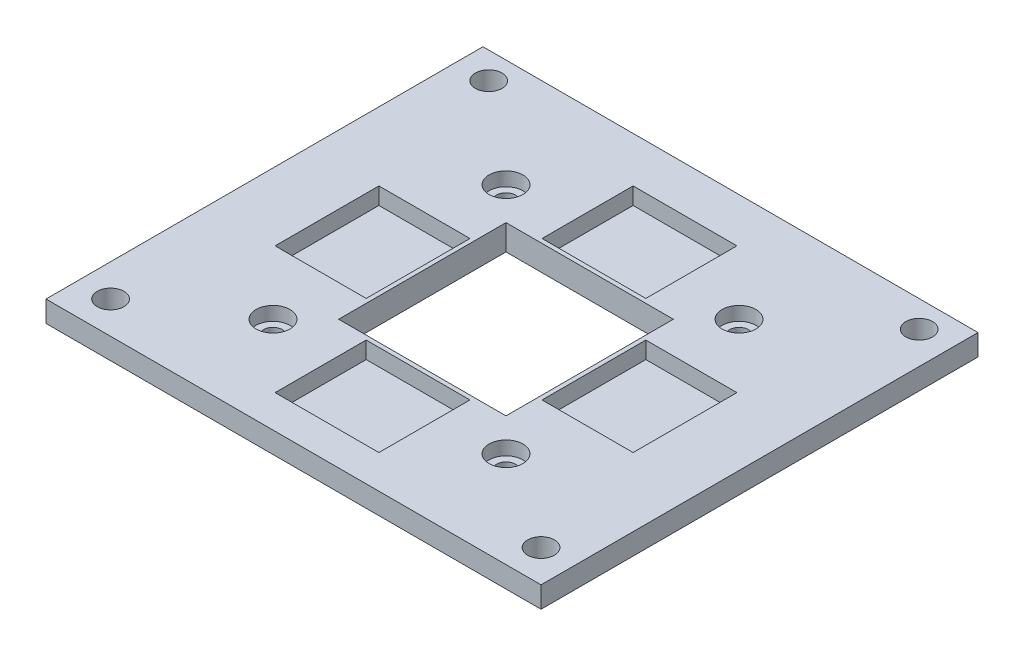
from build123d import *

# Parameters (mm, degrees)
SKETCH1_W              = 116.84
SKETCH1_H              = 103.134084814
SKETCH1_R              = 3.15
BOSS_EXTRUDE1_DEPTH    = 5
SKETCH12_W             = 85
SKETCH12_H             = 23.975046692
BOSS_EXTRUDE15_DEPTH   = 5
SKETCH17_W             = 50
SKETCH17_H             = 50
BOSS_EXTRUDE18_DEPTH   = 6
SKETCH10_W             = 39.5
SKETCH10_H             = 39.5
BOSS_EXTRUDE19_DEPTH   = 25
SKETCH19_W             = 55
SKETCH19_H             = 55
BOSS_EXTRUDE20_DEPTH   = 11
SKETCH20_R             = 2.25
BOSS_EXTRUDE22_DEPTH   = 25
BOSS_EXTRUDE22_2_DEPTH = 25
BOSS_EXTRUDE22_3_DEPTH = 25
BOSS_EXTRUDE22_4_DEPTH = 25
SKETCH21_W             = 24.5
SKETCH21_H             = 21.5
BOSS_EXTRUDE23_DEPTH   = 4
SKETCH21_W_2           = 21.5
SKETCH21_H_2           = 24.5
BOSS_EXTRUDE23_2_DEPTH = 4
BOSS_EXTRUDE23_3_DEPTH = 4
BOSS_EXTRUDE23_4_DEPTH = 4
SKETCH25_R             = 4
BOSS_EXTRUDE24_DEPTH   = 3.25
BOSS_EXTRUDE24_2_DEPTH = 3.25
BOSS_EXTRUDE24_3_DEPTH = 3.25
BOSS_EXTRUDE24_4_DEPTH = 3.25


with BuildPart() as part:
    # Sketch1 → Boss-Extrude1 (new body)
    with BuildSketch(Plane(origin=(0, 0, 0), x_dir=(1, 0, 0), z_dir=(0, 1, 0))):
        with Locations((0, 1.415042407)):
            Rectangle(SKETCH1_W, SKETCH1_H)
        with Locations((-50.8, 46.711)):
            Circle(SKETCH1_R, mode=Mode.SUBTRACT)
        with Locations((50.8, -42.532)):
            Circle(SKETCH1_R, mode=Mode.SUBTRACT)
        with Locations((-50.8, -42.532)):
            Circle(SKETCH1_R, mode=Mode.SUBTRACT)
        with Locations((50.8, 46.711)):
            Circle(SKETCH1_R, mode=Mode.SUBTRACT)
    extrude(amount=-BOSS_EXTRUDE1_DEPTH)


with BuildPart() as body_2:
    # Sketch12 → Boss-Extrude15 (new body)
    with BuildSketch(Plane(origin=(0, 0, 0), x_dir=(1, 0, 0), z_dir=(0, 1, 0))):
        with Locations((0, 58)):
            Rectangle(SKETCH12_W, SKETCH12_H)
    extrude(amount=BOSS_EXTRUDE15_DEPTH)


with BuildPart() as body_3:
    # Sketch17 → Boss-Extrude18 (new body)
    with BuildSketch(Plane(origin=(0, 0, 0), x_dir=(1, 0, 0), z_dir=(0, 1, 0))):
        Rectangle(SKETCH17_W, SKETCH17_H)
    extrude(amount=-BOSS_EXTRUDE18_DEPTH)


with BuildPart() as body_4:
    # Sketch10 → Boss-Extrude19 (new body, symmetric)
    with BuildSketch(Plane(origin=(0, 0, 0), x_dir=(1, 0, 0), z_dir=(0, 1, 0))):
        Rectangle(SKETCH10_W, SKETCH10_H)
    extrude(amount=BOSS_EXTRUDE19_DEPTH, both=True)


with BuildPart() as body_5:
    # Sketch19 → Boss-Extrude20 (new body)
    with BuildSketch(Plane(origin=(0, 0, 0), x_dir=(1, 0, 0), z_dir=(0, 1, 0))):
        Rectangle(SKETCH19_W, SKETCH19_H)
    extrude(amount=-BOSS_EXTRUDE20_DEPTH)


with BuildPart() as part_1:
    add(part.part)

    # Combine1: cut body 2
    add(body_2.part, mode=Mode.SUBTRACT)


with BuildPart() as body_3_1:
    # Body-Move/Copy4: moved
    add(body_3.part.moved(Location((0, -6, 0))))


with BuildPart() as body_5_1:
    add(body_5.part)

    # Combine4: cut body 3
    add(body_3_1.part, mode=Mode.SUBTRACT)

    # Combine7: union part
    add(part_1.part)

    # Combine8: cut body 4
    add(body_4.part, mode=Mode.SUBTRACT)


with BuildPart() as body_2_2:
    # Sketch20 → Boss-Extrude22 (new body, symmetric)
    with BuildSketch(Plane(origin=(0, 0, 0), x_dir=(1, 0, 0), z_dir=(0, 1, 0))):
        with Locations((27.5, 27.5)):
            Circle(SKETCH20_R)
    extrude(amount=BOSS_EXTRUDE22_DEPTH, both=True)


with BuildPart() as body_3_2:
    # Sketch20 → Boss-Extrude22 2 (new body, symmetric)
    with BuildSketch(Plane(origin=(0, 0, 0), x_dir=(1, 0, 0), z_dir=(0, 1, 0))):
        with Locations((27.5, -27.5)):
            Circle(SKETCH20_R)
    extrude(amount=BOSS_EXTRUDE22_2_DEPTH, both=True)


with BuildPart() as body_4_2:
    # Sketch20 → Boss-Extrude22 3 (new body, symmetric)
    with BuildSketch(Plane(origin=(0, 0, 0), x_dir=(1, 0, 0), z_dir=(0, 1, 0))):
        with Locations((-27.5, -27.5)):
            Circle(SKETCH20_R)
    extrude(amount=BOSS_EXTRUDE22_3_DEPTH, both=True)


with BuildPart() as body_5_2:
    # Sketch20 → Boss-Extrude22 4 (new body, symmetric)
    with BuildSketch(Plane(origin=(0, 0, 0), x_dir=(1, 0, 0), z_dir=(0, 1, 0))):
        with Locations((-27.5, 27.5)):
            Circle(SKETCH20_R)
    extrude(amount=BOSS_EXTRUDE22_4_DEPTH, both=True)


with BuildPart() as body_5_3:
    add(body_5_1.part)

    # Combine9: cut body 4 2, body 3 2, body 2 2, body 5 2
    add(body_4_2.part, mode=Mode.SUBTRACT)
    add(body_3_2.part, mode=Mode.SUBTRACT)
    add(body_2_2.part, mode=Mode.SUBTRACT)
    add(body_5_2.part, mode=Mode.SUBTRACT)


with BuildPart() as body_2_3:
    # Sketch21 → Boss-Extrude23 (new body)
    with BuildSketch(Plane(origin=(0, 0, 0), x_dir=(1, 0, 0), z_dir=(0, 1, 0))):
        with Locations((0, 31.5)):
            Rectangle(SKETCH21_W, SKETCH21_H)
    extrude(amount=-BOSS_EXTRUDE23_DEPTH)


with BuildPart() as body_3_3:
    # Sketch21 → Boss-Extrude23 2 (new body)
    with BuildSketch(Plane(origin=(0, 0, 0), x_dir=(1, 0, 0), z_dir=(0, 1, 0))):
        with Locations((31.5, 0)):
            Rectangle(SKETCH21_W_2, SKETCH21_H_2)
    extrude(amount=-BOSS_EXTRUDE23_2_DEPTH)


with BuildPart() as body_4_3:
    # Sketch21 → Boss-Extrude23 3 (new body)
    with BuildSketch(Plane(origin=(0, 0, 0), x_dir=(1, 0, 0), z_dir=(0, 1, 0))):
        with Locations((-31.5, 0)):
            Rectangle(SKETCH21_W_2, SKETCH21_H_2)
    extrude(amount=-BOSS_EXTRUDE23_3_DEPTH)


with BuildPart() as body_5_3_1:
    # Sketch21 → Boss-Extrude23 4 (new body)
    with BuildSketch(Plane(origin=(0, 0, 0), x_dir=(1, 0, 0), z_dir=(0, 1, 0))):
        with Locations((0, -31.5)):
            Rectangle(SKETCH21_W, SKETCH21_H)
    extrude(amount=-BOSS_EXTRUDE23_4_DEPTH)


with BuildPart() as body_5_4:
    add(body_5_3.part)

    # Combine10: cut body 3 3, body 2 3, body 5 3, body 4 3
    add(body_3_3.part, mode=Mode.SUBTRACT)
    add(body_2_3.part, mode=Mode.SUBTRACT)
    add(body_5_3_1.part, mode=Mode.SUBTRACT)
    add(body_4_3.part, mode=Mode.SUBTRACT)


with BuildPart() as body_2_4:
    # Sketch25 → Boss-Extrude24 (new body)
    with BuildSketch(Plane(origin=(0, 0, 0), x_dir=(1, 0, 0), z_dir=(0, 1, 0))):
        with Locations((27.5, 27.5)):
            Circle(SKETCH25_R)
    extrude(amount=-BOSS_EXTRUDE24_DEPTH)


with BuildPart() as body_3_4:
    # Sketch25 → Boss-Extrude24 2 (new body)
    with BuildSketch(Plane(origin=(0, 0, 0), x_dir=(1, 0, 0), z_dir=(0, 1, 0))):
        with Locations((-27.5, 27.5)):
            Circle(SKETCH25_R)
    extrude(amount=-BOSS_EXTRUDE24_2_DEPTH)


with BuildPart() as body_4_4:
    # Sketch25 → Boss-Extrude24 3 (new body)
    with BuildSketch(Plane(origin=(0, 0, 0), x_dir=(1, 0, 0), z_dir=(0, 1, 0))):
        with Locations((-27.5, -27.5)):
            Circle(SKETCH25_R)
    extrude(amount=-BOSS_EXTRUDE24_3_DEPTH)


with BuildPart() as body_5_4_1:
    # Sketch25 → Boss-Extrude24 4 (new body)
    with BuildSketch(Plane(origin=(0, 0, 0), x_dir=(1, 0, 0), z_dir=(0, 1, 0))):
        with Locations((27.5, -27.5)):
            Circle(SKETCH25_R)
    extrude(amount=-BOSS_EXTRUDE24_4_DEPTH)


with BuildPart() as body_5_5:
    add(body_5_4.part)

    # Combine11: cut body 4 4, body 3 4, body 2 4, body 5 4
    add(body_4_4.part, mode=Mode.SUBTRACT)
    add(body_3_4.part, mode=Mode.SUBTRACT)
    add(body_2_4.part, mode=Mode.SUBTRACT)
    add(body_5_4_1.part, mode=Mode.SUBTRACT)


solid = body_5_5.part
